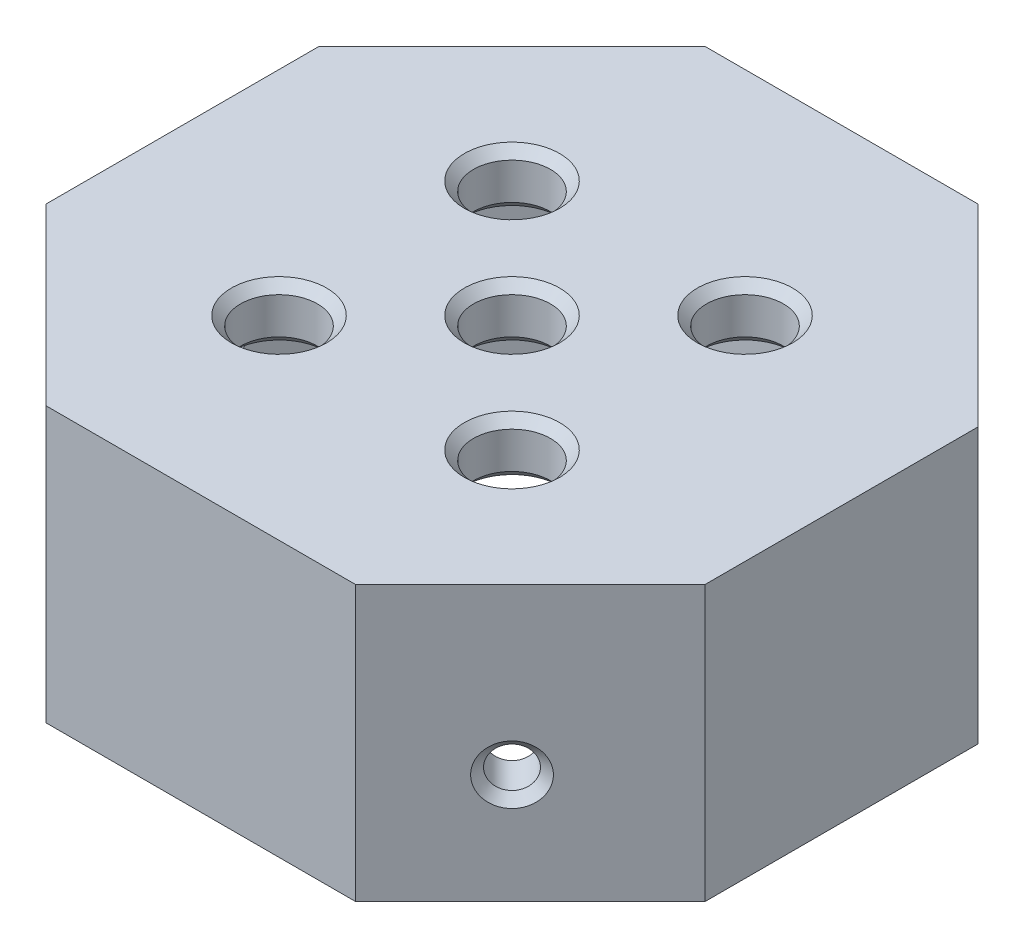
from build123d import *

# Parameters (mm, degrees)
EXTRUDE_1_DEPTH     = 12
EXTRUDE_2_DEPTH     = 3
CHAMFER_1_SIZE      = 1
SKETCH_3_R          = 2.1
CUT_EXTRUDE_1_DEPTH = 16
CHAMFER_3_SIZE      = 0.5
SKETCH_4_R          = 1.1
CUT_EXTRUDE_2_DEPTH = 44.455844123
SKETCH_5_R          = 1.1
CUT_EXTRUDE_3_DEPTH = 44.455844123
SKETCH_6_R          = 1.1
CUT_EXTRUDE_4_DEPTH = 2.5
CHAMFER_4_SIZE      = 0.5
CHAMFER_5_SIZE      = 0.5
CUT_EXTRUDE_5_DEPTH = 16


with BuildPart() as part:
    # Эскиз1 → Бобышка-Вытянуть1 (new body)
    with BuildSketch(Plane(origin=(0, 0, 0), x_dir=(1, 0, 0), z_dir=(0, 1, 0))):
        Polygon((-7.455844123, 18), (-18, 7.455844123), (-18, -7.455844123), (-7.455844123, -18), (7.455844123, -18), (18, -7.455844123), (18, 7.455844123), (7.455844123, 18), align=None)
        Polygon((-6.420310217, 15.5), (-15.5, 6.420310217), (-15.5, -6.420310217), (-6.420310217, -15.5), (6.420310217, -15.5), (15.5, -6.420310217), (15.5, 6.420310217), (6.420310217, 15.5), align=None, mode=Mode.SUBTRACT)
    extrude(amount=EXTRUDE_1_DEPTH)

    # Эскиз2 → Бобышка-Вытянуть2 (add)
    with BuildSketch(Plane(origin=(0, 12, 0), x_dir=(1, 0, 0), z_dir=(0, 1, 0))):
        Polygon((7.455844123, 18), (-7.455844123, 18), (-18, 7.455844123), (-18, -7.455844123), (-7.455844123, -18), (7.455844123, -18), (18, -7.455844123), (18, 7.455844123), align=None)
    extrude(amount=EXTRUDE_2_DEPTH)

    # Фаска1
    chamfer_1_edges = [part.edges().sort_by_distance(p)[0] for p in [
        (0, 12, -15.5),
        (-10.960155108, 12, -10.960155108),
        (-15.5, 12, 0),
        (-10.960155108, 12, 10.960155108),
        (0, 12, 15.5),
        (10.960155108, 12, 10.960155108),
        (15.5, 12, 0),
        (10.960155108, 12, -10.960155108),
    ]]
    chamfer(chamfer_1_edges, length=CHAMFER_1_SIZE)

    # Эскиз3 → Вырез-Вытянуть1 (cut, through all)
    with BuildSketch(Plane(origin=(0, 15, 0), x_dir=(1, 0, 0), z_dir=(0, 1, 0))):
        Circle(SKETCH_3_R)
        with Locations((-6.363961031, 6.363961031)):
            Circle(SKETCH_3_R)
        with Locations((6.363961031, 6.363961031)):
            Circle(SKETCH_3_R)
        with Locations((6.363961031, -6.363961031)):
            Circle(SKETCH_3_R)
        with Locations((-6.363961031, -6.363961031)):
            Circle(SKETCH_3_R)
    extrude(amount=-CUT_EXTRUDE_1_DEPTH, mode=Mode.SUBTRACT)

    # Фаска3
    chamfer_3_edges = [part.edges().sort_by_distance(p)[0] for p in [
        (-2.1, 12, 0),
        (-8.463961031, 12, -6.363961031),
        (4.263961031, 12, -6.363961031),
        (4.263961031, 12, 6.363961031),
        (-8.463961031, 12, 6.363961031),
    ]]
    chamfer(chamfer_3_edges, length=CHAMFER_3_SIZE)

    # Эскиз4 → Вырез-Вытянуть2 (cut, through all)
    with BuildSketch(Plane(origin=(-12.727922061, 0, 12.727922061), x_dir=(0.707106781, 0, 0.707106781), z_dir=(-0.707106781, 0, 0.707106781))):
        with Locations((0, 6)):
            Circle(SKETCH_4_R)
    extrude(amount=-CUT_EXTRUDE_2_DEPTH, mode=Mode.SUBTRACT)

    # Эскиз5 → Вырез-Вытянуть3 (cut, through all)
    with BuildSketch(Plane(origin=(12.727922061, 0, 12.727922061), x_dir=(0.707106781, 0, -0.707106781), z_dir=(0.707106781, 0, 0.707106781))):
        with Locations((0, 6)):
            Circle(SKETCH_5_R)
    extrude(amount=-CUT_EXTRUDE_3_DEPTH, mode=Mode.SUBTRACT)

    # Эскиз6 → Вырез-Вытянуть4 (cut)
    with BuildSketch(Plane.ZY.offset(18)):
        with Locations((0, 6)):
            Circle(SKETCH_6_R)
    extrude(amount=-CUT_EXTRUDE_4_DEPTH, mode=Mode.SUBTRACT)

    # Фаска4
    chamfer_4_edges = [part.edges().sort_by_distance(p)[0] for p in [
        (11.950104602, 6, -13.505739521),
        (-13.505739521, 6, 11.950104602),
        (-13.505739521, 6, -11.950104602),
        (11.950104602, 6, 13.505739521),
        (-18, 6, -1.1),
    ]]
    chamfer(chamfer_4_edges, length=CHAMFER_4_SIZE)

    # Фаска5
    chamfer_5_edges = [part.edges().sort_by_distance(p)[0] for p in [
        (-2.1, 15, 0),
        (-8.463961031, 15, -6.363961031),
        (4.263961031, 15, -6.363961031),
        (4.263961031, 15, 6.363961031),
        (-8.463961031, 15, 6.363961031),
    ]]
    chamfer(chamfer_5_edges, length=CHAMFER_5_SIZE)

    # Эскиз9 → Вырез-Вытянуть5 (cut, through all)
    with BuildSketch(Plane.XZ):
        Polygon((-8.455844123, 17), (-7.455844123, 18), (7.455844123, 18), (8.455844123, 17), align=None)
    extrude(amount=-CUT_EXTRUDE_5_DEPTH, mode=Mode.SUBTRACT)


solid = part.part
